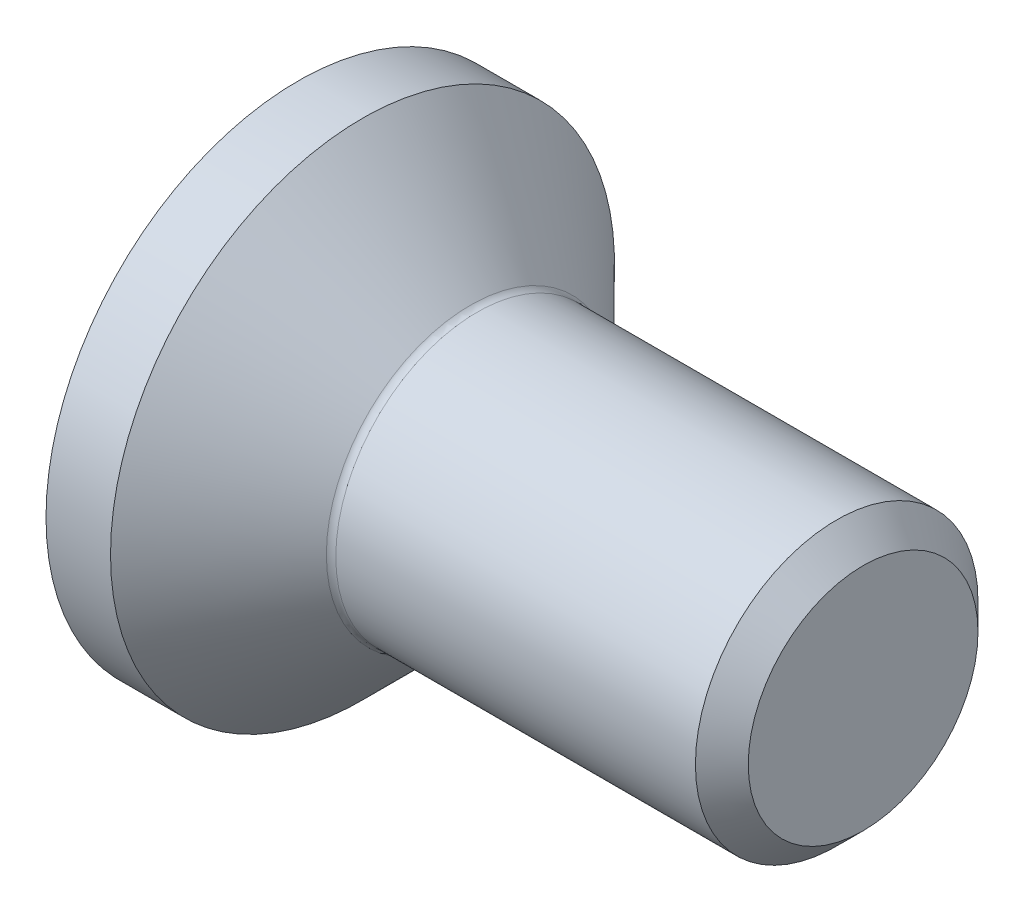
from build123d import *

# Parameters (mm, degrees)
FILLET1_R   = 0.1
HEX_2_DEPTH = 1.1


with BuildPart() as part:
    # BodySke → BaseBody (revolve)
    with BuildSketch(Plane.XY):
        Polygon((0, 0), (0, 2.675), (0.685, 2.675), (1.86, 1.5), (5.7195, 1.5), (6, 1.2195), (6, 0), align=None)
    revolve(axis=Axis((0, 0, 0), (1, 0, 0)))

    # Fillet1
    fillet1_edges = [part.edges().sort_by_distance(p)[0] for p in [
        (1.86, -1.5, 0),
    ]]
    fillet(fillet1_edges, radius=FILLET1_R)

    # Sketch2 → PreBroach (revolve, cut)
    with BuildSketch(Plane.XY):
        Polygon((0, 1), (1.1, 1), (1.677350269, 0), (0, 0), align=None)
    revolve(axis=Axis((0, 0, 0), (1, 0, 0)), mode=Mode.SUBTRACT)

    # Sketch3 → Hex 2 (cut)
    with BuildSketch(Plane.ZY):
        Polygon((-1, -0.577350269), (-1, 0.577350269), (0, 1.154700538), (1, 0.577350269), (1, -0.577350269), (0, -1.154700538), align=None)
    extrude(amount=-HEX_2_DEPTH, mode=Mode.SUBTRACT)


solid = part.part
